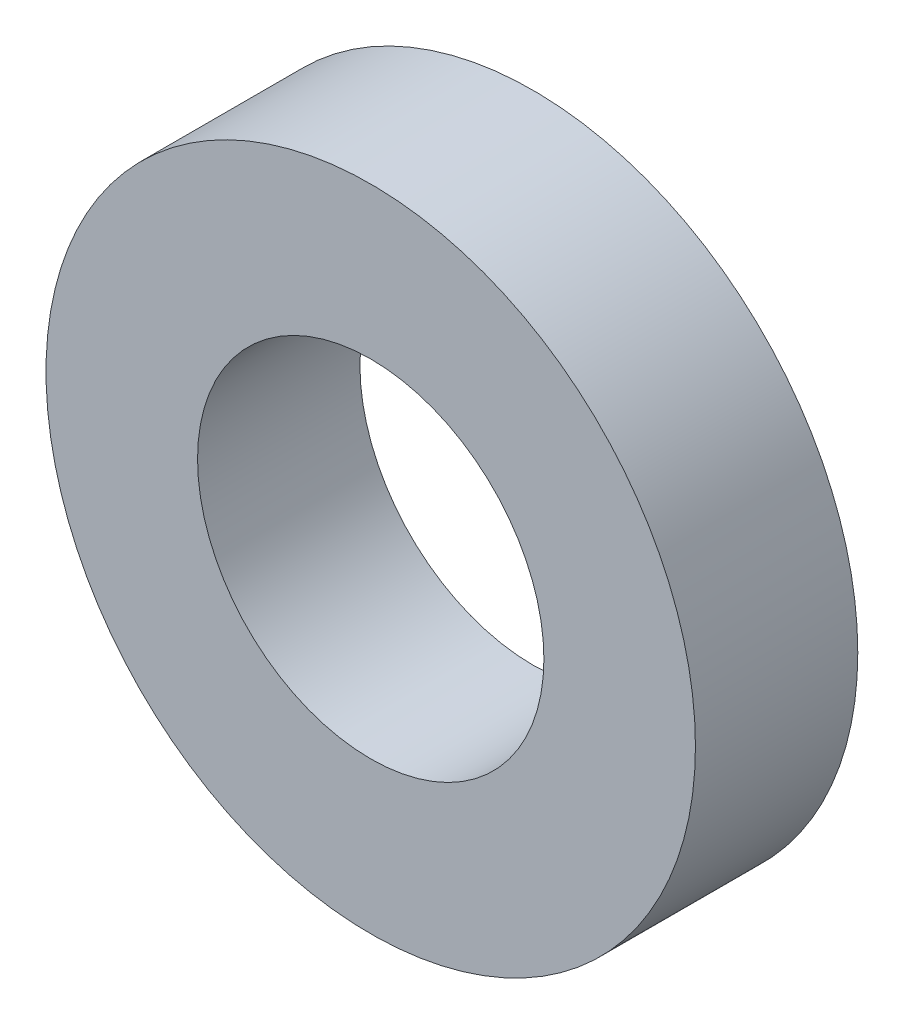
from build123d import *

# Parameters (mm, degrees)
SKETCH1_R           = 3
SKETCH1_R_2         = 1.6
BOSS_EXTRUDE1_DEPTH = 1.5


with BuildPart() as part:
    # Sketch1 → Boss-Extrude1 (new body)
    with BuildSketch(Plane(origin=(0, 0, 0), x_dir=(0, 1, 0), z_dir=(0, 0, 1))):
        Circle(SKETCH1_R)
        Circle(SKETCH1_R_2, mode=Mode.SUBTRACT)
    extrude(amount=BOSS_EXTRUDE1_DEPTH)


solid = part.part
